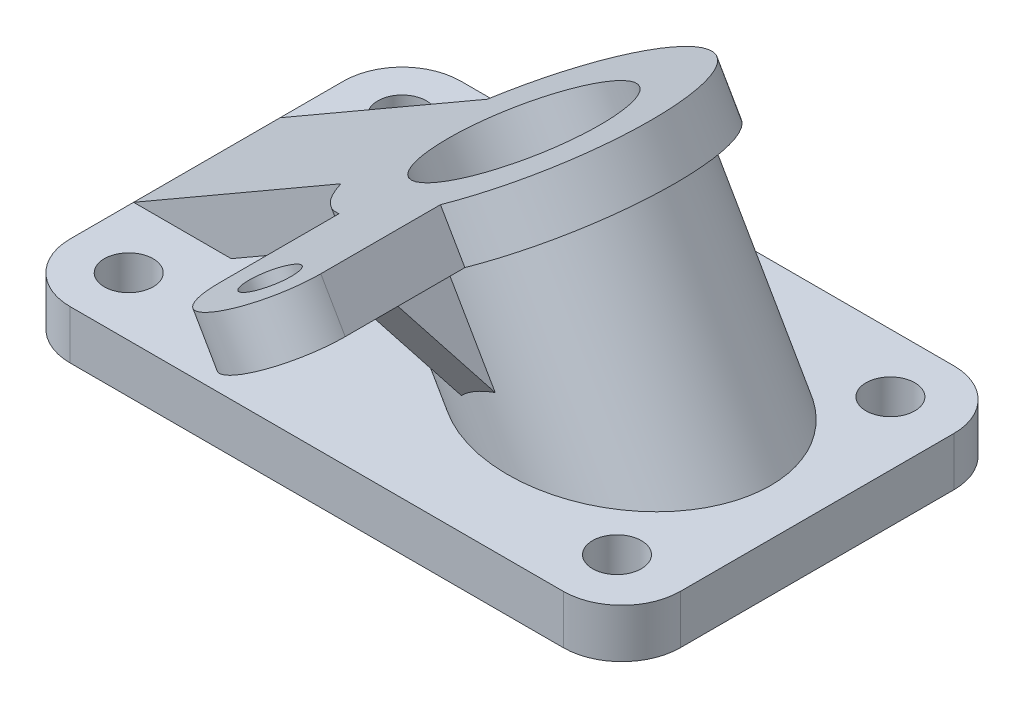
from build123d import *

# Parameters (mm, degrees)
SKETCH_1_R          = 5
EXTRUDE_1_DEPTH     = 10
SKETCH_3_R          = 5
SKETCH_3_R_2        = 18
EXTRUDE_3_DEPTH     = 10
EXTRUDE_4_REACH     = 73.16
SKETCH_4_R          = 25
SKETCH_5_R          = 18
CUT_EXTRUDE_1_DEPTH = 72.160254038
EXTRUDE_6_DEPTH     = 4


with BuildPart() as part:
    # 草图1 → 凸台-拉伸1 (new body)
    with BuildSketch(Plane(origin=(0, 0, 0), x_dir=(1, 0, 0), z_dir=(0, 1, 0))):
        with BuildLine():
            Line((-69.708508874, 31.297621281), (31.291491126, 31.297621281))
            ThreePointArc((31.291491126, 31.297621281), (39.7767725, 27.782902656), (43.291491126, 19.297621281))
            Line((43.291491126, 19.297621281), (43.291491126, -36.702378719))
            ThreePointArc((43.291491126, -36.702378719), (39.7767725, -45.187660093), (31.291491126, -48.702378719))
            Line((31.291491126, -48.702378719), (-69.708508874, -48.702378719))
            ThreePointArc((-69.708508874, -48.702378719), (-78.193790248, -45.187660093), (-81.708508874, -36.702378719))
            Line((-81.708508874, -36.702378719), (-81.708508874, 19.297621281))
            ThreePointArc((-81.708508874, 19.297621281), (-78.193790248, 27.782902656), (-69.708508874, 31.297621281))
        make_face()
        with Locations((-69.708508874, -36.702378719)):
            Circle(SKETCH_1_R, mode=Mode.SUBTRACT)
        with Locations((30.291491126, -36.702378719)):
            Circle(SKETCH_1_R, mode=Mode.SUBTRACT)
        with Locations((30.291491126, 19.297621281)):
            Circle(SKETCH_1_R, mode=Mode.SUBTRACT)
        with Locations((-69.708508874, 19.297621281)):
            Circle(SKETCH_1_R, mode=Mode.SUBTRACT)
    extrude(amount=EXTRUDE_1_DEPTH)

    # 草图3 → 凸台-拉伸3 (add)
    with BuildSketch(Plane(origin=(-24.757254237, 42.880822195, 0), x_dir=(0, 0, 1), z_dir=(-0.5, 0.866025404, 0))):
        with BuildLine():
            Line((-6.297621281, -65.76164439), (-6.297621281, -16.742406504))
            ThreePointArc((-6.297621281, -16.742406504), (-11.289336226, 31.606443002), (36.197832888, 21.23835561))
            Line((36.197832888, 21.23835561), (60.702378719, 21.23835561))
            ThreePointArc((60.702378719, 21.23835561), (72.702378719, 9.23835561), (60.702378719, -2.76164439))
            Line((60.702378719, -2.76164439), (36.197832888, -2.76164439))
            ThreePointArc((36.197832888, -2.76164439), (31.070466111, -10.753359335), (23.702378719, -16.742406504))
            Line((23.702378719, -16.742406504), (23.702378719, -65.76164439))
            Line((23.702378719, -65.76164439), (-6.297621281, -65.76164439))
        make_face()
        with Locations((60.702378719, 9.23835561)):
            Circle(SKETCH_3_R, mode=Mode.SUBTRACT)
        with Locations((8.702378719, 9.23835561)):
            Circle(SKETCH_3_R_2, mode=Mode.SUBTRACT)
    extrude(amount=-EXTRUDE_3_DEPTH)

    # 草图4 → 凸台-拉伸4 (add, up to next)
    with BuildSketch(Plane(origin=(-24.757254237, 42.880822195, 0), x_dir=(0, 0, 1), z_dir=(-0.5, 0.866025404, 0)), mode=Mode.PRIVATE) as extrude_4_sk1:
        with Locations((8.702378719, 9.23835561)):
            Circle(SKETCH_4_R)
    extrude_4_tool1 = extrude(extrude_4_sk1.sketch, amount=-EXTRUDE_4_REACH, mode=Mode.PRIVATE) - part.part
    add(extrude_4_tool1.solids().sort_by_distance((-16.756604, 47.5, 8.702379))[0])

    # 草图5 → 切除-拉伸1 (cut, through all)
    with BuildSketch(Plane(origin=(-24.757254237, 42.880822195, 0), x_dir=(0.866025404, 0.5, 0), z_dir=(-0.5, 0.866025404, 0))):
        with Locations((9.23835561, -8.702378719)):
            Circle(SKETCH_5_R)
    extrude(amount=-CUT_EXTRUDE_1_DEPTH, mode=Mode.SUBTRACT)

    # 草图7 → 凸台-拉伸6 (add, symmetric)
    with BuildSketch(Plane(origin=(8.000650647, 4.619177805, 0), x_dir=(0, 0, 1), z_dir=(-0.866025404, -0.5, 0))):
        Polygon((45.297720901, 39.514508475), (30.011923646, 39.514508475), (30.472342637, 13.83620008), align=None)
    extrude(amount=EXTRUDE_6_DEPTH, both=True)


solid = part.part
